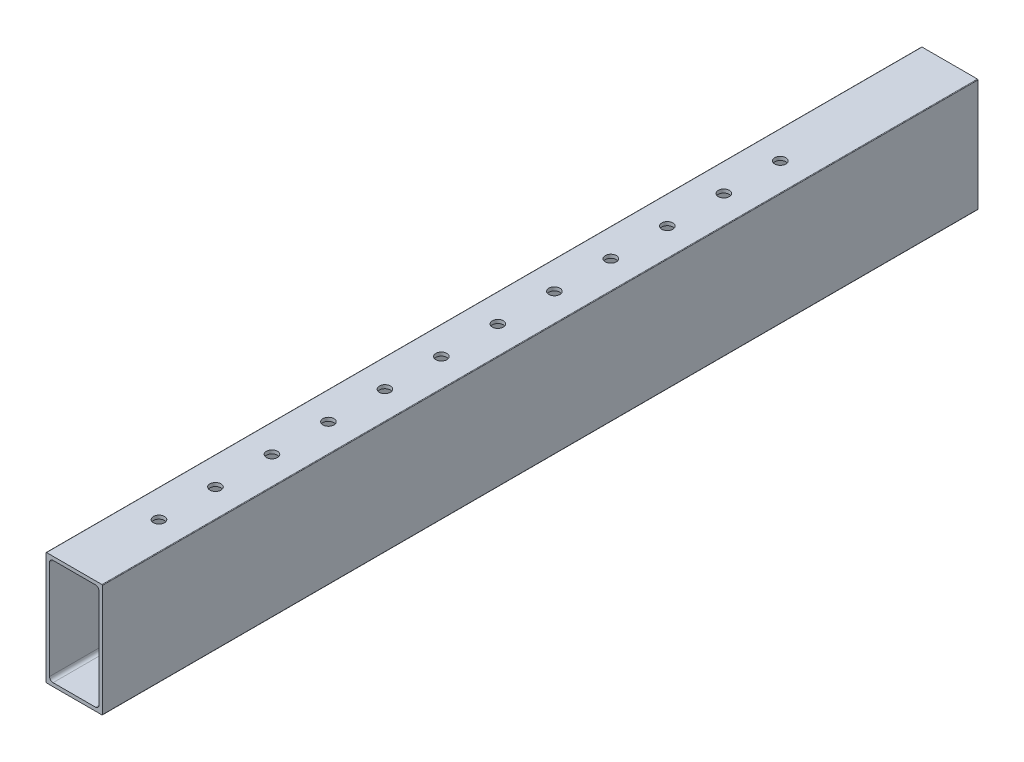
from build123d import *

# Parameters (mm, degrees)
BOSS_EXTRUDE1_START = -88.9
BOSS_EXTRUDE1_DEPTH = 393.7
SKETCH3_R           = 2.4892
CUT_EXTRUDE2_DEPTH  = 51.8


with BuildPart() as part:
    # Sketch1 → Boss-Extrude1 (new body)
    with BuildSketch(Plane(origin=(0, 0, 0), x_dir=(-1, 0, 0), z_dir=(0, 0, -1)).offset(BOSS_EXTRUDE1_START)):
        with BuildLine():
            Line((-12.7, 25.146), (-12.7, -25.146))
            ThreePointArc((-12.7, -25.146), (-12.625605122, -25.325605122), (-12.446, -25.4))
            Line((-12.446, -25.4), (12.446, -25.4))
            ThreePointArc((12.446, -25.4), (12.625605122, -25.325605122), (12.7, -25.146))
            Line((12.7, -25.146), (12.7, 25.146))
            ThreePointArc((12.7, 25.146), (12.625605122, 25.325605122), (12.446, 25.4))
            Line((12.446, 25.4), (-12.446, 25.4))
            ThreePointArc((-12.446, 25.4), (-12.625605122, 25.325605122), (-12.7, 25.146))
        make_face()
        with BuildLine():
            Line((-11.1125, -22.225), (-11.1125, 22.225))
            ThreePointArc((-11.1125, 22.225), (-10.647532015, 23.347532015), (-9.525, 23.8125))
            Line((-9.525, 23.8125), (9.525, 23.8125))
            ThreePointArc((9.525, 23.8125), (10.647532015, 23.347532015), (11.1125, 22.225))
            Line((11.1125, 22.225), (11.1125, -22.225))
            ThreePointArc((11.1125, -22.225), (10.647532015, -23.347532015), (9.525, -23.8125))
            Line((9.525, -23.8125), (-9.525, -23.8125))
            ThreePointArc((-9.525, -23.8125), (-10.647532015, -23.347532015), (-11.1125, -22.225))
        make_face(mode=Mode.SUBTRACT)
    extrude(amount=-BOSS_EXTRUDE1_DEPTH)

    # Sketch3 → Cut-Extrude2 (cut, through all)
    with BuildSketch(Plane.XZ.offset(25.4)):
        with Locations((0, 165.1)):
            Circle(SKETCH3_R)
        with Locations((0, 190.5)):
            Circle(SKETCH3_R)
        with Locations((0, 215.9)):
            Circle(SKETCH3_R)
        with Locations((0, 241.3)):
            Circle(SKETCH3_R)
        with Locations((0, 266.7)):
            Circle(SKETCH3_R)
        with Locations((0, 292.1)):
            Circle(SKETCH3_R)
        with Locations((0, 317.5)):
            Circle(SKETCH3_R)
        with Locations((0, 342.9)):
            Circle(SKETCH3_R)
        with Locations((0, 368.3)):
            Circle(SKETCH3_R)
        with Locations((0, 393.7)):
            Circle(SKETCH3_R)
        with Locations((0, 419.1)):
            Circle(SKETCH3_R)
        with Locations((0, 444.5)):
            Circle(SKETCH3_R)
    extrude(amount=-CUT_EXTRUDE2_DEPTH, mode=Mode.SUBTRACT)


solid = part.part
